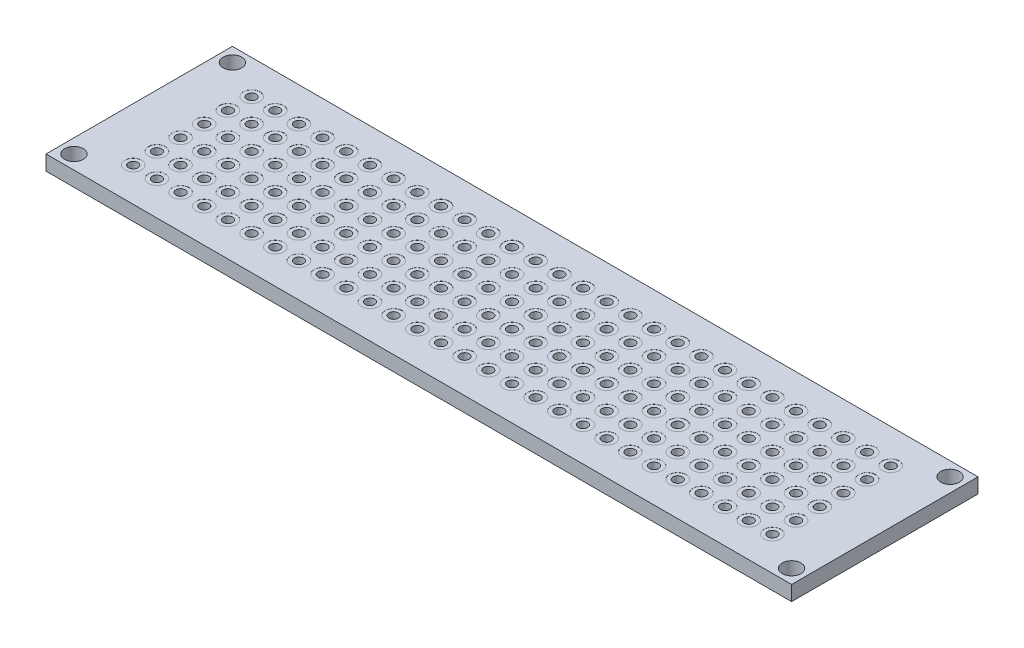
from build123d import *

# Parameters (mm, degrees)
SKETCH1_W           = 80
SKETCH1_H           = 20
SKETCH1_R           = 0.5
SKETCH1_R_2         = 1
BOSS_EXTRUDE1_DEPTH = 1.6
SKETCH2_R           = 0.9
CUT_EXTRUDE1_DEPTH  = 0.01
SKETCH3_R           = 0.9
CUT_EXTRUDE2_DEPTH  = 0.01


with BuildPart() as part:
    # Sketch1 → Boss-Extrude1 (new body)
    with BuildSketch(Plane(origin=(0, 0, 0), x_dir=(1, 0, 0), z_dir=(0, 1, 0))):
        with Locations((40, 10)):
            Rectangle(SKETCH1_W, SKETCH1_H)
        with Locations((5.71, 16.35)):
            Circle(SKETCH1_R, mode=Mode.SUBTRACT)
        with Locations((5.71, 13.81)):
            Circle(SKETCH1_R, mode=Mode.SUBTRACT)
        with Locations((5.71, 11.27)):
            Circle(SKETCH1_R, mode=Mode.SUBTRACT)
        with Locations((5.71, 8.73)):
            Circle(SKETCH1_R, mode=Mode.SUBTRACT)
        with Locations((5.71, 6.19)):
            Circle(SKETCH1_R, mode=Mode.SUBTRACT)
        with Locations((5.71, 3.65)):
            Circle(SKETCH1_R, mode=Mode.SUBTRACT)
        with Locations((8.25, 16.35)):
            Circle(SKETCH1_R, mode=Mode.SUBTRACT)
        with Locations((8.25, 13.81)):
            Circle(SKETCH1_R, mode=Mode.SUBTRACT)
        with Locations((8.25, 11.27)):
            Circle(SKETCH1_R, mode=Mode.SUBTRACT)
        with Locations((8.25, 8.73)):
            Circle(SKETCH1_R, mode=Mode.SUBTRACT)
        with Locations((8.25, 6.19)):
            Circle(SKETCH1_R, mode=Mode.SUBTRACT)
        with Locations((8.25, 3.65)):
            Circle(SKETCH1_R, mode=Mode.SUBTRACT)
        with Locations((10.79, 16.35)):
            Circle(SKETCH1_R, mode=Mode.SUBTRACT)
        with Locations((10.79, 13.81)):
            Circle(SKETCH1_R, mode=Mode.SUBTRACT)
        with Locations((10.79, 11.27)):
            Circle(SKETCH1_R, mode=Mode.SUBTRACT)
        with Locations((10.79, 8.73)):
            Circle(SKETCH1_R, mode=Mode.SUBTRACT)
        with Locations((10.79, 6.19)):
            Circle(SKETCH1_R, mode=Mode.SUBTRACT)
        with Locations((10.79, 3.65)):
            Circle(SKETCH1_R, mode=Mode.SUBTRACT)
        with Locations((13.33, 16.35)):
            Circle(SKETCH1_R, mode=Mode.SUBTRACT)
        with Locations((13.33, 13.81)):
            Circle(SKETCH1_R, mode=Mode.SUBTRACT)
        with Locations((13.33, 11.27)):
            Circle(SKETCH1_R, mode=Mode.SUBTRACT)
        with Locations((13.33, 8.73)):
            Circle(SKETCH1_R, mode=Mode.SUBTRACT)
        with Locations((13.33, 6.19)):
            Circle(SKETCH1_R, mode=Mode.SUBTRACT)
        with Locations((13.33, 3.65)):
            Circle(SKETCH1_R, mode=Mode.SUBTRACT)
        with Locations((15.87, 16.35)):
            Circle(SKETCH1_R, mode=Mode.SUBTRACT)
        with Locations((15.87, 13.81)):
            Circle(SKETCH1_R, mode=Mode.SUBTRACT)
        with Locations((15.87, 11.27)):
            Circle(SKETCH1_R, mode=Mode.SUBTRACT)
        with Locations((15.87, 8.73)):
            Circle(SKETCH1_R, mode=Mode.SUBTRACT)
        with Locations((15.87, 6.19)):
            Circle(SKETCH1_R, mode=Mode.SUBTRACT)
        with Locations((15.87, 3.65)):
            Circle(SKETCH1_R, mode=Mode.SUBTRACT)
        with Locations((18.41, 16.35)):
            Circle(SKETCH1_R, mode=Mode.SUBTRACT)
        with Locations((18.41, 13.81)):
            Circle(SKETCH1_R, mode=Mode.SUBTRACT)
        with Locations((18.41, 11.27)):
            Circle(SKETCH1_R, mode=Mode.SUBTRACT)
        with Locations((18.41, 8.73)):
            Circle(SKETCH1_R, mode=Mode.SUBTRACT)
        with Locations((18.41, 6.19)):
            Circle(SKETCH1_R, mode=Mode.SUBTRACT)
        with Locations((18.41, 3.65)):
            Circle(SKETCH1_R, mode=Mode.SUBTRACT)
        with Locations((20.95, 16.35)):
            Circle(SKETCH1_R, mode=Mode.SUBTRACT)
        with Locations((20.95, 13.81)):
            Circle(SKETCH1_R, mode=Mode.SUBTRACT)
        with Locations((20.95, 11.27)):
            Circle(SKETCH1_R, mode=Mode.SUBTRACT)
        with Locations((20.95, 8.73)):
            Circle(SKETCH1_R, mode=Mode.SUBTRACT)
        with Locations((20.95, 6.19)):
            Circle(SKETCH1_R, mode=Mode.SUBTRACT)
        with Locations((20.95, 3.65)):
            Circle(SKETCH1_R, mode=Mode.SUBTRACT)
        with Locations((23.49, 16.35)):
            Circle(SKETCH1_R, mode=Mode.SUBTRACT)
        with Locations((23.49, 13.81)):
            Circle(SKETCH1_R, mode=Mode.SUBTRACT)
        with Locations((23.49, 11.27)):
            Circle(SKETCH1_R, mode=Mode.SUBTRACT)
        with Locations((23.49, 8.73)):
            Circle(SKETCH1_R, mode=Mode.SUBTRACT)
        with Locations((23.49, 6.19)):
            Circle(SKETCH1_R, mode=Mode.SUBTRACT)
        with Locations((23.49, 3.65)):
            Circle(SKETCH1_R, mode=Mode.SUBTRACT)
        with Locations((26.03, 16.35)):
            Circle(SKETCH1_R, mode=Mode.SUBTRACT)
        with Locations((26.03, 13.81)):
            Circle(SKETCH1_R, mode=Mode.SUBTRACT)
        with Locations((26.03, 11.27)):
            Circle(SKETCH1_R, mode=Mode.SUBTRACT)
        with Locations((26.03, 8.73)):
            Circle(SKETCH1_R, mode=Mode.SUBTRACT)
        with Locations((26.03, 6.19)):
            Circle(SKETCH1_R, mode=Mode.SUBTRACT)
        with Locations((26.03, 3.65)):
            Circle(SKETCH1_R, mode=Mode.SUBTRACT)
        with Locations((28.57, 16.35)):
            Circle(SKETCH1_R, mode=Mode.SUBTRACT)
        with Locations((28.57, 13.81)):
            Circle(SKETCH1_R, mode=Mode.SUBTRACT)
        with Locations((28.57, 11.27)):
            Circle(SKETCH1_R, mode=Mode.SUBTRACT)
        with Locations((28.57, 8.73)):
            Circle(SKETCH1_R, mode=Mode.SUBTRACT)
        with Locations((28.57, 6.19)):
            Circle(SKETCH1_R, mode=Mode.SUBTRACT)
        with Locations((28.57, 3.65)):
            Circle(SKETCH1_R, mode=Mode.SUBTRACT)
        with Locations((31.11, 16.35)):
            Circle(SKETCH1_R, mode=Mode.SUBTRACT)
        with Locations((31.11, 13.81)):
            Circle(SKETCH1_R, mode=Mode.SUBTRACT)
        with Locations((31.11, 11.27)):
            Circle(SKETCH1_R, mode=Mode.SUBTRACT)
        with Locations((31.11, 8.73)):
            Circle(SKETCH1_R, mode=Mode.SUBTRACT)
        with Locations((31.11, 6.19)):
            Circle(SKETCH1_R, mode=Mode.SUBTRACT)
        with Locations((31.11, 3.65)):
            Circle(SKETCH1_R, mode=Mode.SUBTRACT)
        with Locations((33.65, 16.35)):
            Circle(SKETCH1_R, mode=Mode.SUBTRACT)
        with Locations((33.65, 13.81)):
            Circle(SKETCH1_R, mode=Mode.SUBTRACT)
        with Locations((33.65, 11.27)):
            Circle(SKETCH1_R, mode=Mode.SUBTRACT)
        with Locations((33.65, 8.73)):
            Circle(SKETCH1_R, mode=Mode.SUBTRACT)
        with Locations((33.65, 6.19)):
            Circle(SKETCH1_R, mode=Mode.SUBTRACT)
        with Locations((33.65, 3.65)):
            Circle(SKETCH1_R, mode=Mode.SUBTRACT)
        with Locations((36.19, 16.35)):
            Circle(SKETCH1_R, mode=Mode.SUBTRACT)
        with Locations((36.19, 13.81)):
            Circle(SKETCH1_R, mode=Mode.SUBTRACT)
        with Locations((36.19, 11.27)):
            Circle(SKETCH1_R, mode=Mode.SUBTRACT)
        with Locations((36.19, 8.73)):
            Circle(SKETCH1_R, mode=Mode.SUBTRACT)
        with Locations((36.19, 6.19)):
            Circle(SKETCH1_R, mode=Mode.SUBTRACT)
        with Locations((36.19, 3.65)):
            Circle(SKETCH1_R, mode=Mode.SUBTRACT)
        with Locations((38.73, 16.35)):
            Circle(SKETCH1_R, mode=Mode.SUBTRACT)
        with Locations((38.73, 13.81)):
            Circle(SKETCH1_R, mode=Mode.SUBTRACT)
        with Locations((38.73, 11.27)):
            Circle(SKETCH1_R, mode=Mode.SUBTRACT)
        with Locations((38.73, 8.73)):
            Circle(SKETCH1_R, mode=Mode.SUBTRACT)
        with Locations((38.73, 6.19)):
            Circle(SKETCH1_R, mode=Mode.SUBTRACT)
        with Locations((38.73, 3.65)):
            Circle(SKETCH1_R, mode=Mode.SUBTRACT)
        with Locations((41.27, 16.35)):
            Circle(SKETCH1_R, mode=Mode.SUBTRACT)
        with Locations((41.27, 13.81)):
            Circle(SKETCH1_R, mode=Mode.SUBTRACT)
        with Locations((41.27, 11.27)):
            Circle(SKETCH1_R, mode=Mode.SUBTRACT)
        with Locations((41.27, 8.73)):
            Circle(SKETCH1_R, mode=Mode.SUBTRACT)
        with Locations((41.27, 6.19)):
            Circle(SKETCH1_R, mode=Mode.SUBTRACT)
        with Locations((41.27, 3.65)):
            Circle(SKETCH1_R, mode=Mode.SUBTRACT)
        with Locations((43.81, 16.35)):
            Circle(SKETCH1_R, mode=Mode.SUBTRACT)
        with Locations((43.81, 13.81)):
            Circle(SKETCH1_R, mode=Mode.SUBTRACT)
        with Locations((43.81, 11.27)):
            Circle(SKETCH1_R, mode=Mode.SUBTRACT)
        with Locations((43.81, 8.73)):
            Circle(SKETCH1_R, mode=Mode.SUBTRACT)
        with Locations((43.81, 6.19)):
            Circle(SKETCH1_R, mode=Mode.SUBTRACT)
        with Locations((43.81, 3.65)):
            Circle(SKETCH1_R, mode=Mode.SUBTRACT)
        with Locations((46.35, 16.35)):
            Circle(SKETCH1_R, mode=Mode.SUBTRACT)
        with Locations((46.35, 13.81)):
            Circle(SKETCH1_R, mode=Mode.SUBTRACT)
        with Locations((46.35, 11.27)):
            Circle(SKETCH1_R, mode=Mode.SUBTRACT)
        with Locations((46.35, 8.73)):
            Circle(SKETCH1_R, mode=Mode.SUBTRACT)
        with Locations((46.35, 6.19)):
            Circle(SKETCH1_R, mode=Mode.SUBTRACT)
        with Locations((46.35, 3.65)):
            Circle(SKETCH1_R, mode=Mode.SUBTRACT)
        with Locations((48.89, 16.35)):
            Circle(SKETCH1_R, mode=Mode.SUBTRACT)
        with Locations((48.89, 13.81)):
            Circle(SKETCH1_R, mode=Mode.SUBTRACT)
        with Locations((48.89, 11.27)):
            Circle(SKETCH1_R, mode=Mode.SUBTRACT)
        with Locations((48.89, 8.73)):
            Circle(SKETCH1_R, mode=Mode.SUBTRACT)
        with Locations((48.89, 6.19)):
            Circle(SKETCH1_R, mode=Mode.SUBTRACT)
        with Locations((48.89, 3.65)):
            Circle(SKETCH1_R, mode=Mode.SUBTRACT)
        with Locations((51.43, 16.35)):
            Circle(SKETCH1_R, mode=Mode.SUBTRACT)
        with Locations((51.43, 13.81)):
            Circle(SKETCH1_R, mode=Mode.SUBTRACT)
        with Locations((51.43, 11.27)):
            Circle(SKETCH1_R, mode=Mode.SUBTRACT)
        with Locations((51.43, 8.73)):
            Circle(SKETCH1_R, mode=Mode.SUBTRACT)
        with Locations((51.43, 6.19)):
            Circle(SKETCH1_R, mode=Mode.SUBTRACT)
        with Locations((51.43, 3.65)):
            Circle(SKETCH1_R, mode=Mode.SUBTRACT)
        with Locations((53.97, 16.35)):
            Circle(SKETCH1_R, mode=Mode.SUBTRACT)
        with Locations((53.97, 13.81)):
            Circle(SKETCH1_R, mode=Mode.SUBTRACT)
        with Locations((53.97, 11.27)):
            Circle(SKETCH1_R, mode=Mode.SUBTRACT)
        with Locations((53.97, 8.73)):
            Circle(SKETCH1_R, mode=Mode.SUBTRACT)
        with Locations((53.97, 6.19)):
            Circle(SKETCH1_R, mode=Mode.SUBTRACT)
        with Locations((53.97, 3.65)):
            Circle(SKETCH1_R, mode=Mode.SUBTRACT)
        with Locations((56.51, 16.35)):
            Circle(SKETCH1_R, mode=Mode.SUBTRACT)
        with Locations((56.51, 13.81)):
            Circle(SKETCH1_R, mode=Mode.SUBTRACT)
        with Locations((56.51, 11.27)):
            Circle(SKETCH1_R, mode=Mode.SUBTRACT)
        with Locations((56.51, 8.73)):
            Circle(SKETCH1_R, mode=Mode.SUBTRACT)
        with Locations((56.51, 6.19)):
            Circle(SKETCH1_R, mode=Mode.SUBTRACT)
        with Locations((56.51, 3.65)):
            Circle(SKETCH1_R, mode=Mode.SUBTRACT)
        with Locations((59.05, 16.35)):
            Circle(SKETCH1_R, mode=Mode.SUBTRACT)
        with Locations((59.05, 13.81)):
            Circle(SKETCH1_R, mode=Mode.SUBTRACT)
        with Locations((59.05, 11.27)):
            Circle(SKETCH1_R, mode=Mode.SUBTRACT)
        with Locations((59.05, 8.73)):
            Circle(SKETCH1_R, mode=Mode.SUBTRACT)
        with Locations((59.05, 6.19)):
            Circle(SKETCH1_R, mode=Mode.SUBTRACT)
        with Locations((59.05, 3.65)):
            Circle(SKETCH1_R, mode=Mode.SUBTRACT)
        with Locations((61.59, 16.35)):
            Circle(SKETCH1_R, mode=Mode.SUBTRACT)
        with Locations((61.59, 13.81)):
            Circle(SKETCH1_R, mode=Mode.SUBTRACT)
        with Locations((61.59, 11.27)):
            Circle(SKETCH1_R, mode=Mode.SUBTRACT)
        with Locations((61.59, 8.73)):
            Circle(SKETCH1_R, mode=Mode.SUBTRACT)
        with Locations((61.59, 6.19)):
            Circle(SKETCH1_R, mode=Mode.SUBTRACT)
        with Locations((61.59, 3.65)):
            Circle(SKETCH1_R, mode=Mode.SUBTRACT)
        with Locations((64.13, 16.35)):
            Circle(SKETCH1_R, mode=Mode.SUBTRACT)
        with Locations((64.13, 13.81)):
            Circle(SKETCH1_R, mode=Mode.SUBTRACT)
        with Locations((64.13, 11.27)):
            Circle(SKETCH1_R, mode=Mode.SUBTRACT)
        with Locations((64.13, 8.73)):
            Circle(SKETCH1_R, mode=Mode.SUBTRACT)
        with Locations((64.13, 6.19)):
            Circle(SKETCH1_R, mode=Mode.SUBTRACT)
        with Locations((64.13, 3.65)):
            Circle(SKETCH1_R, mode=Mode.SUBTRACT)
        with Locations((66.67, 16.35)):
            Circle(SKETCH1_R, mode=Mode.SUBTRACT)
        with Locations((66.67, 13.81)):
            Circle(SKETCH1_R, mode=Mode.SUBTRACT)
        with Locations((66.67, 11.27)):
            Circle(SKETCH1_R, mode=Mode.SUBTRACT)
        with Locations((66.67, 8.73)):
            Circle(SKETCH1_R, mode=Mode.SUBTRACT)
        with Locations((66.67, 6.19)):
            Circle(SKETCH1_R, mode=Mode.SUBTRACT)
        with Locations((66.67, 3.65)):
            Circle(SKETCH1_R, mode=Mode.SUBTRACT)
        with Locations((69.21, 16.35)):
            Circle(SKETCH1_R, mode=Mode.SUBTRACT)
        with Locations((69.21, 13.81)):
            Circle(SKETCH1_R, mode=Mode.SUBTRACT)
        with Locations((69.21, 11.27)):
            Circle(SKETCH1_R, mode=Mode.SUBTRACT)
        with Locations((69.21, 8.73)):
            Circle(SKETCH1_R, mode=Mode.SUBTRACT)
        with Locations((69.21, 6.19)):
            Circle(SKETCH1_R, mode=Mode.SUBTRACT)
        with Locations((69.21, 3.65)):
            Circle(SKETCH1_R, mode=Mode.SUBTRACT)
        with Locations((71.75, 16.35)):
            Circle(SKETCH1_R, mode=Mode.SUBTRACT)
        with Locations((71.75, 13.81)):
            Circle(SKETCH1_R, mode=Mode.SUBTRACT)
        with Locations((71.75, 11.27)):
            Circle(SKETCH1_R, mode=Mode.SUBTRACT)
        with Locations((71.75, 8.73)):
            Circle(SKETCH1_R, mode=Mode.SUBTRACT)
        with Locations((71.75, 6.19)):
            Circle(SKETCH1_R, mode=Mode.SUBTRACT)
        with Locations((71.75, 3.65)):
            Circle(SKETCH1_R, mode=Mode.SUBTRACT)
        with Locations((74.29, 16.35)):
            Circle(SKETCH1_R, mode=Mode.SUBTRACT)
        with Locations((74.29, 13.81)):
            Circle(SKETCH1_R, mode=Mode.SUBTRACT)
        with Locations((74.29, 11.27)):
            Circle(SKETCH1_R, mode=Mode.SUBTRACT)
        with Locations((74.29, 8.73)):
            Circle(SKETCH1_R, mode=Mode.SUBTRACT)
        with Locations((74.29, 6.19)):
            Circle(SKETCH1_R, mode=Mode.SUBTRACT)
        with Locations((74.29, 3.65)):
            Circle(SKETCH1_R, mode=Mode.SUBTRACT)
        with Locations((1.5, 18.5)):
            Circle(SKETCH1_R_2, mode=Mode.SUBTRACT)
        with Locations((78.5, 18.5)):
            Circle(SKETCH1_R_2, mode=Mode.SUBTRACT)
        with Locations((1.5, 1.5)):
            Circle(SKETCH1_R_2, mode=Mode.SUBTRACT)
        with Locations((78.5, 1.5)):
            Circle(SKETCH1_R_2, mode=Mode.SUBTRACT)
    extrude(amount=BOSS_EXTRUDE1_DEPTH)

    # Sketch2 → Cut-Extrude1 (cut)
    with BuildSketch(Plane(origin=(0, 1.6, 0), x_dir=(1, 0, 0), z_dir=(0, 1, 0))):
        with Locations((5.71, 16.35)):
            Circle(SKETCH2_R)
        with Locations((8.25, 16.35)):
            Circle(SKETCH2_R)
        with Locations((10.79, 16.35)):
            Circle(SKETCH2_R)
        with Locations((13.33, 16.35)):
            Circle(SKETCH2_R)
        with Locations((15.87, 16.35)):
            Circle(SKETCH2_R)
        with Locations((18.41, 16.35)):
            Circle(SKETCH2_R)
        with Locations((20.95, 16.35)):
            Circle(SKETCH2_R)
        with Locations((23.49, 16.35)):
            Circle(SKETCH2_R)
        with Locations((26.03, 16.35)):
            Circle(SKETCH2_R)
        with Locations((28.57, 16.35)):
            Circle(SKETCH2_R)
        with Locations((31.11, 16.35)):
            Circle(SKETCH2_R)
        with Locations((33.65, 16.35)):
            Circle(SKETCH2_R)
        with Locations((36.19, 16.35)):
            Circle(SKETCH2_R)
        with Locations((38.73, 16.35)):
            Circle(SKETCH2_R)
        with Locations((41.27, 16.35)):
            Circle(SKETCH2_R)
        with Locations((43.81, 16.35)):
            Circle(SKETCH2_R)
        with Locations((46.35, 16.35)):
            Circle(SKETCH2_R)
        with Locations((48.89, 16.35)):
            Circle(SKETCH2_R)
        with Locations((51.43, 16.35)):
            Circle(SKETCH2_R)
        with Locations((53.97, 16.35)):
            Circle(SKETCH2_R)
        with Locations((56.51, 16.35)):
            Circle(SKETCH2_R)
        with Locations((59.05, 16.35)):
            Circle(SKETCH2_R)
        with Locations((61.59, 16.35)):
            Circle(SKETCH2_R)
        with Locations((64.13, 16.35)):
            Circle(SKETCH2_R)
        with Locations((66.67, 16.35)):
            Circle(SKETCH2_R)
        with Locations((69.21, 16.35)):
            Circle(SKETCH2_R)
        with Locations((71.75, 16.35)):
            Circle(SKETCH2_R)
        with Locations((74.29, 16.35)):
            Circle(SKETCH2_R)
        with Locations((8.25, 13.81)):
            Circle(SKETCH2_R)
        with Locations((10.79, 13.81)):
            Circle(SKETCH2_R)
        with Locations((13.33, 13.81)):
            Circle(SKETCH2_R)
        with Locations((15.87, 13.81)):
            Circle(SKETCH2_R)
        with Locations((18.41, 13.81)):
            Circle(SKETCH2_R)
        with Locations((20.95, 13.81)):
            Circle(SKETCH2_R)
        with Locations((23.49, 13.81)):
            Circle(SKETCH2_R)
        with Locations((26.03, 13.81)):
            Circle(SKETCH2_R)
        with Locations((28.57, 13.81)):
            Circle(SKETCH2_R)
        with Locations((31.11, 13.81)):
            Circle(SKETCH2_R)
        with Locations((33.65, 13.81)):
            Circle(SKETCH2_R)
        with Locations((36.19, 13.81)):
            Circle(SKETCH2_R)
        with Locations((38.73, 13.81)):
            Circle(SKETCH2_R)
        with Locations((41.27, 13.81)):
            Circle(SKETCH2_R)
        with Locations((43.81, 13.81)):
            Circle(SKETCH2_R)
        with Locations((46.35, 13.81)):
            Circle(SKETCH2_R)
        with Locations((48.89, 13.81)):
            Circle(SKETCH2_R)
        with Locations((51.43, 13.81)):
            Circle(SKETCH2_R)
        with Locations((53.97, 13.81)):
            Circle(SKETCH2_R)
        with Locations((56.51, 13.81)):
            Circle(SKETCH2_R)
        with Locations((59.05, 13.81)):
            Circle(SKETCH2_R)
        with Locations((61.59, 13.81)):
            Circle(SKETCH2_R)
        with Locations((64.13, 13.81)):
            Circle(SKETCH2_R)
        with Locations((66.67, 13.81)):
            Circle(SKETCH2_R)
        with Locations((69.21, 13.81)):
            Circle(SKETCH2_R)
        with Locations((71.75, 13.81)):
            Circle(SKETCH2_R)
        with Locations((74.29, 13.81)):
            Circle(SKETCH2_R)
        with Locations((8.25, 11.27)):
            Circle(SKETCH2_R)
        with Locations((10.79, 11.27)):
            Circle(SKETCH2_R)
        with Locations((13.33, 11.27)):
            Circle(SKETCH2_R)
        with Locations((15.87, 11.27)):
            Circle(SKETCH2_R)
        with Locations((18.41, 11.27)):
            Circle(SKETCH2_R)
        with Locations((20.95, 11.27)):
            Circle(SKETCH2_R)
        with Locations((23.49, 11.27)):
            Circle(SKETCH2_R)
        with Locations((26.03, 11.27)):
            Circle(SKETCH2_R)
        with Locations((28.57, 11.27)):
            Circle(SKETCH2_R)
        with Locations((31.11, 11.27)):
            Circle(SKETCH2_R)
        with Locations((33.65, 11.27)):
            Circle(SKETCH2_R)
        with Locations((36.19, 11.27)):
            Circle(SKETCH2_R)
        with Locations((38.73, 11.27)):
            Circle(SKETCH2_R)
        with Locations((41.27, 11.27)):
            Circle(SKETCH2_R)
        with Locations((43.81, 11.27)):
            Circle(SKETCH2_R)
        with Locations((46.35, 11.27)):
            Circle(SKETCH2_R)
        with Locations((48.89, 11.27)):
            Circle(SKETCH2_R)
        with Locations((51.43, 11.27)):
            Circle(SKETCH2_R)
        with Locations((53.97, 11.27)):
            Circle(SKETCH2_R)
        with Locations((56.51, 11.27)):
            Circle(SKETCH2_R)
        with Locations((59.05, 11.27)):
            Circle(SKETCH2_R)
        with Locations((61.59, 11.27)):
            Circle(SKETCH2_R)
        with Locations((64.13, 11.27)):
            Circle(SKETCH2_R)
        with Locations((66.67, 11.27)):
            Circle(SKETCH2_R)
        with Locations((69.21, 11.27)):
            Circle(SKETCH2_R)
        with Locations((71.75, 11.27)):
            Circle(SKETCH2_R)
        with Locations((74.29, 11.27)):
            Circle(SKETCH2_R)
        with Locations((8.25, 8.73)):
            Circle(SKETCH2_R)
        with Locations((10.79, 8.73)):
            Circle(SKETCH2_R)
        with Locations((13.33, 8.73)):
            Circle(SKETCH2_R)
        with Locations((15.87, 8.73)):
            Circle(SKETCH2_R)
        with Locations((18.41, 8.73)):
            Circle(SKETCH2_R)
        with Locations((20.95, 8.73)):
            Circle(SKETCH2_R)
        with Locations((23.49, 8.73)):
            Circle(SKETCH2_R)
        with Locations((26.03, 8.73)):
            Circle(SKETCH2_R)
        with Locations((28.57, 8.73)):
            Circle(SKETCH2_R)
        with Locations((31.11, 8.73)):
            Circle(SKETCH2_R)
        with Locations((33.65, 8.73)):
            Circle(SKETCH2_R)
        with Locations((36.19, 8.73)):
            Circle(SKETCH2_R)
        with Locations((38.73, 8.73)):
            Circle(SKETCH2_R)
        with Locations((41.27, 8.73)):
            Circle(SKETCH2_R)
        with Locations((43.81, 8.73)):
            Circle(SKETCH2_R)
        with Locations((46.35, 8.73)):
            Circle(SKETCH2_R)
        with Locations((48.89, 8.73)):
            Circle(SKETCH2_R)
        with Locations((51.43, 8.73)):
            Circle(SKETCH2_R)
        with Locations((53.97, 8.73)):
            Circle(SKETCH2_R)
        with Locations((56.51, 8.73)):
            Circle(SKETCH2_R)
        with Locations((59.05, 8.73)):
            Circle(SKETCH2_R)
        with Locations((61.59, 8.73)):
            Circle(SKETCH2_R)
        with Locations((64.13, 8.73)):
            Circle(SKETCH2_R)
        with Locations((66.67, 8.73)):
            Circle(SKETCH2_R)
        with Locations((69.21, 8.73)):
            Circle(SKETCH2_R)
        with Locations((71.75, 8.73)):
            Circle(SKETCH2_R)
        with Locations((74.29, 8.73)):
            Circle(SKETCH2_R)
        with Locations((8.25, 6.19)):
            Circle(SKETCH2_R)
        with Locations((10.79, 6.19)):
            Circle(SKETCH2_R)
        with Locations((13.33, 6.19)):
            Circle(SKETCH2_R)
        with Locations((15.87, 6.19)):
            Circle(SKETCH2_R)
        with Locations((18.41, 6.19)):
            Circle(SKETCH2_R)
        with Locations((20.95, 6.19)):
            Circle(SKETCH2_R)
        with Locations((23.49, 6.19)):
            Circle(SKETCH2_R)
        with Locations((26.03, 6.19)):
            Circle(SKETCH2_R)
        with Locations((28.57, 6.19)):
            Circle(SKETCH2_R)
        with Locations((31.11, 6.19)):
            Circle(SKETCH2_R)
        with Locations((33.65, 6.19)):
            Circle(SKETCH2_R)
        with Locations((36.19, 6.19)):
            Circle(SKETCH2_R)
        with Locations((38.73, 6.19)):
            Circle(SKETCH2_R)
        with Locations((41.27, 6.19)):
            Circle(SKETCH2_R)
        with Locations((43.81, 6.19)):
            Circle(SKETCH2_R)
        with Locations((46.35, 6.19)):
            Circle(SKETCH2_R)
        with Locations((48.89, 6.19)):
            Circle(SKETCH2_R)
        with Locations((51.43, 6.19)):
            Circle(SKETCH2_R)
        with Locations((53.97, 6.19)):
            Circle(SKETCH2_R)
        with Locations((56.51, 6.19)):
            Circle(SKETCH2_R)
        with Locations((59.05, 6.19)):
            Circle(SKETCH2_R)
        with Locations((61.59, 6.19)):
            Circle(SKETCH2_R)
        with Locations((64.13, 6.19)):
            Circle(SKETCH2_R)
        with Locations((66.67, 6.19)):
            Circle(SKETCH2_R)
        with Locations((69.21, 6.19)):
            Circle(SKETCH2_R)
        with Locations((71.75, 6.19)):
            Circle(SKETCH2_R)
        with Locations((74.29, 6.19)):
            Circle(SKETCH2_R)
        with Locations((8.25, 3.65)):
            Circle(SKETCH2_R)
        with Locations((10.79, 3.65)):
            Circle(SKETCH2_R)
        with Locations((13.33, 3.65)):
            Circle(SKETCH2_R)
        with Locations((15.87, 3.65)):
            Circle(SKETCH2_R)
        with Locations((18.41, 3.65)):
            Circle(SKETCH2_R)
        with Locations((20.95, 3.65)):
            Circle(SKETCH2_R)
        with Locations((23.49, 3.65)):
            Circle(SKETCH2_R)
        with Locations((26.03, 3.65)):
            Circle(SKETCH2_R)
        with Locations((28.57, 3.65)):
            Circle(SKETCH2_R)
        with Locations((31.11, 3.65)):
            Circle(SKETCH2_R)
        with Locations((33.65, 3.65)):
            Circle(SKETCH2_R)
        with Locations((36.19, 3.65)):
            Circle(SKETCH2_R)
        with Locations((38.73, 3.65)):
            Circle(SKETCH2_R)
        with Locations((41.27, 3.65)):
            Circle(SKETCH2_R)
        with Locations((43.81, 3.65)):
            Circle(SKETCH2_R)
        with Locations((46.35, 3.65)):
            Circle(SKETCH2_R)
        with Locations((48.89, 3.65)):
            Circle(SKETCH2_R)
        with Locations((51.43, 3.65)):
            Circle(SKETCH2_R)
        with Locations((53.97, 3.65)):
            Circle(SKETCH2_R)
        with Locations((56.51, 3.65)):
            Circle(SKETCH2_R)
        with Locations((59.05, 3.65)):
            Circle(SKETCH2_R)
        with Locations((61.59, 3.65)):
            Circle(SKETCH2_R)
        with Locations((64.13, 3.65)):
            Circle(SKETCH2_R)
        with Locations((66.67, 3.65)):
            Circle(SKETCH2_R)
        with Locations((69.21, 3.65)):
            Circle(SKETCH2_R)
        with Locations((71.75, 3.65)):
            Circle(SKETCH2_R)
        with Locations((74.29, 3.65)):
            Circle(SKETCH2_R)
        with Locations((5.71, 13.81)):
            Circle(SKETCH2_R)
        with Locations((5.71, 11.27)):
            Circle(SKETCH2_R)
        with Locations((5.71, 8.73)):
            Circle(SKETCH2_R)
        with Locations((5.71, 6.19)):
            Circle(SKETCH2_R)
        with Locations((5.71, 3.65)):
            Circle(SKETCH2_R)
    extrude(amount=-CUT_EXTRUDE1_DEPTH, mode=Mode.SUBTRACT)

    # Sketch3 → Cut-Extrude2 (cut)
    with BuildSketch(Plane.XZ):
        with Locations((20.95, -3.65)):
            Circle(SKETCH3_R)
        with Locations((18.41, -3.65)):
            Circle(SKETCH3_R)
        with Locations((15.87, -3.65)):
            Circle(SKETCH3_R)
        with Locations((13.33, -3.65)):
            Circle(SKETCH3_R)
        with Locations((10.79, -3.65)):
            Circle(SKETCH3_R)
        with Locations((8.25, -3.65)):
            Circle(SKETCH3_R)
        with Locations((74.29, -6.19)):
            Circle(SKETCH3_R)
        with Locations((71.75, -6.19)):
            Circle(SKETCH3_R)
        with Locations((18.41, -16.35)):
            Circle(SKETCH3_R)
        with Locations((15.87, -16.35)):
            Circle(SKETCH3_R)
        with Locations((13.33, -16.35)):
            Circle(SKETCH3_R)
        with Locations((10.79, -16.35)):
            Circle(SKETCH3_R)
        with Locations((8.25, -16.35)):
            Circle(SKETCH3_R)
        with Locations((5.71, -16.35)):
            Circle(SKETCH3_R)
        with Locations((41.27, -3.65)):
            Circle(SKETCH3_R)
        with Locations((38.73, -3.65)):
            Circle(SKETCH3_R)
        with Locations((36.19, -3.65)):
            Circle(SKETCH3_R)
        with Locations((33.65, -3.65)):
            Circle(SKETCH3_R)
        with Locations((31.11, -3.65)):
            Circle(SKETCH3_R)
        with Locations((28.57, -3.65)):
            Circle(SKETCH3_R)
        with Locations((26.03, -3.65)):
            Circle(SKETCH3_R)
        with Locations((23.49, -3.65)):
            Circle(SKETCH3_R)
        with Locations((38.73, -16.35)):
            Circle(SKETCH3_R)
        with Locations((36.19, -16.35)):
            Circle(SKETCH3_R)
        with Locations((33.65, -16.35)):
            Circle(SKETCH3_R)
        with Locations((31.11, -16.35)):
            Circle(SKETCH3_R)
        with Locations((28.57, -16.35)):
            Circle(SKETCH3_R)
        with Locations((26.03, -16.35)):
            Circle(SKETCH3_R)
        with Locations((23.49, -16.35)):
            Circle(SKETCH3_R)
        with Locations((20.95, -16.35)):
            Circle(SKETCH3_R)
        with Locations((61.59, -3.65)):
            Circle(SKETCH3_R)
        with Locations((59.05, -3.65)):
            Circle(SKETCH3_R)
        with Locations((56.51, -3.65)):
            Circle(SKETCH3_R)
        with Locations((53.97, -3.65)):
            Circle(SKETCH3_R)
        with Locations((51.43, -3.65)):
            Circle(SKETCH3_R)
        with Locations((48.89, -3.65)):
            Circle(SKETCH3_R)
        with Locations((46.35, -3.65)):
            Circle(SKETCH3_R)
        with Locations((43.81, -3.65)):
            Circle(SKETCH3_R)
        with Locations((59.05, -16.35)):
            Circle(SKETCH3_R)
        with Locations((56.51, -16.35)):
            Circle(SKETCH3_R)
        with Locations((53.97, -16.35)):
            Circle(SKETCH3_R)
        with Locations((51.43, -16.35)):
            Circle(SKETCH3_R)
        with Locations((48.89, -16.35)):
            Circle(SKETCH3_R)
        with Locations((46.35, -16.35)):
            Circle(SKETCH3_R)
        with Locations((43.81, -16.35)):
            Circle(SKETCH3_R)
        with Locations((41.27, -16.35)):
            Circle(SKETCH3_R)
        with Locations((5.71, -8.73)):
            Circle(SKETCH3_R)
        with Locations((5.71, -11.27)):
            Circle(SKETCH3_R)
        with Locations((5.71, -13.81)):
            Circle(SKETCH3_R)
        with Locations((74.29, -3.65)):
            Circle(SKETCH3_R)
        with Locations((71.75, -3.65)):
            Circle(SKETCH3_R)
        with Locations((69.21, -3.65)):
            Circle(SKETCH3_R)
        with Locations((66.67, -3.65)):
            Circle(SKETCH3_R)
        with Locations((64.13, -3.65)):
            Circle(SKETCH3_R)
        with Locations((10.79, -13.81)):
            Circle(SKETCH3_R)
        with Locations((8.25, -13.81)):
            Circle(SKETCH3_R)
        with Locations((74.29, -16.35)):
            Circle(SKETCH3_R)
        with Locations((71.75, -16.35)):
            Circle(SKETCH3_R)
        with Locations((69.21, -16.35)):
            Circle(SKETCH3_R)
        with Locations((66.67, -16.35)):
            Circle(SKETCH3_R)
        with Locations((64.13, -16.35)):
            Circle(SKETCH3_R)
        with Locations((61.59, -16.35)):
            Circle(SKETCH3_R)
        with Locations((5.71, -3.65)):
            Circle(SKETCH3_R)
        with Locations((5.71, -6.19)):
            Circle(SKETCH3_R)
        with Locations((31.11, -13.81)):
            Circle(SKETCH3_R)
        with Locations((28.57, -13.81)):
            Circle(SKETCH3_R)
        with Locations((26.03, -13.81)):
            Circle(SKETCH3_R)
        with Locations((23.49, -13.81)):
            Circle(SKETCH3_R)
        with Locations((20.95, -13.81)):
            Circle(SKETCH3_R)
        with Locations((18.41, -13.81)):
            Circle(SKETCH3_R)
        with Locations((15.87, -13.81)):
            Circle(SKETCH3_R)
        with Locations((13.33, -13.81)):
            Circle(SKETCH3_R)
        with Locations((51.43, -13.81)):
            Circle(SKETCH3_R)
        with Locations((48.89, -13.81)):
            Circle(SKETCH3_R)
        with Locations((46.35, -13.81)):
            Circle(SKETCH3_R)
        with Locations((43.81, -13.81)):
            Circle(SKETCH3_R)
        with Locations((41.27, -13.81)):
            Circle(SKETCH3_R)
        with Locations((38.73, -13.81)):
            Circle(SKETCH3_R)
        with Locations((36.19, -13.81)):
            Circle(SKETCH3_R)
        with Locations((33.65, -13.81)):
            Circle(SKETCH3_R)
        with Locations((71.75, -13.81)):
            Circle(SKETCH3_R)
        with Locations((69.21, -13.81)):
            Circle(SKETCH3_R)
        with Locations((66.67, -13.81)):
            Circle(SKETCH3_R)
        with Locations((64.13, -13.81)):
            Circle(SKETCH3_R)
        with Locations((61.59, -13.81)):
            Circle(SKETCH3_R)
        with Locations((59.05, -13.81)):
            Circle(SKETCH3_R)
        with Locations((56.51, -13.81)):
            Circle(SKETCH3_R)
        with Locations((53.97, -13.81)):
            Circle(SKETCH3_R)
        with Locations((23.49, -11.27)):
            Circle(SKETCH3_R)
        with Locations((20.95, -11.27)):
            Circle(SKETCH3_R)
        with Locations((18.41, -11.27)):
            Circle(SKETCH3_R)
        with Locations((15.87, -11.27)):
            Circle(SKETCH3_R)
        with Locations((13.33, -11.27)):
            Circle(SKETCH3_R)
        with Locations((10.79, -11.27)):
            Circle(SKETCH3_R)
        with Locations((8.25, -11.27)):
            Circle(SKETCH3_R)
        with Locations((74.29, -13.81)):
            Circle(SKETCH3_R)
        with Locations((43.81, -11.27)):
            Circle(SKETCH3_R)
        with Locations((41.27, -11.27)):
            Circle(SKETCH3_R)
        with Locations((38.73, -11.27)):
            Circle(SKETCH3_R)
        with Locations((36.19, -11.27)):
            Circle(SKETCH3_R)
        with Locations((33.65, -11.27)):
            Circle(SKETCH3_R)
        with Locations((31.11, -11.27)):
            Circle(SKETCH3_R)
        with Locations((28.57, -11.27)):
            Circle(SKETCH3_R)
        with Locations((26.03, -11.27)):
            Circle(SKETCH3_R)
        with Locations((64.13, -11.27)):
            Circle(SKETCH3_R)
        with Locations((61.59, -11.27)):
            Circle(SKETCH3_R)
        with Locations((59.05, -11.27)):
            Circle(SKETCH3_R)
        with Locations((56.51, -11.27)):
            Circle(SKETCH3_R)
        with Locations((53.97, -11.27)):
            Circle(SKETCH3_R)
        with Locations((51.43, -11.27)):
            Circle(SKETCH3_R)
        with Locations((48.89, -11.27)):
            Circle(SKETCH3_R)
        with Locations((46.35, -11.27)):
            Circle(SKETCH3_R)
        with Locations((15.87, -8.73)):
            Circle(SKETCH3_R)
        with Locations((13.33, -8.73)):
            Circle(SKETCH3_R)
        with Locations((10.79, -8.73)):
            Circle(SKETCH3_R)
        with Locations((8.25, -8.73)):
            Circle(SKETCH3_R)
        with Locations((74.29, -11.27)):
            Circle(SKETCH3_R)
        with Locations((71.75, -11.27)):
            Circle(SKETCH3_R)
        with Locations((69.21, -11.27)):
            Circle(SKETCH3_R)
        with Locations((66.67, -11.27)):
            Circle(SKETCH3_R)
        with Locations((36.19, -8.73)):
            Circle(SKETCH3_R)
        with Locations((33.65, -8.73)):
            Circle(SKETCH3_R)
        with Locations((31.11, -8.73)):
            Circle(SKETCH3_R)
        with Locations((28.57, -8.73)):
            Circle(SKETCH3_R)
        with Locations((26.03, -8.73)):
            Circle(SKETCH3_R)
        with Locations((23.49, -8.73)):
            Circle(SKETCH3_R)
        with Locations((20.95, -8.73)):
            Circle(SKETCH3_R)
        with Locations((18.41, -8.73)):
            Circle(SKETCH3_R)
        with Locations((56.51, -8.73)):
            Circle(SKETCH3_R)
        with Locations((53.97, -8.73)):
            Circle(SKETCH3_R)
        with Locations((51.43, -8.73)):
            Circle(SKETCH3_R)
        with Locations((48.89, -8.73)):
            Circle(SKETCH3_R)
        with Locations((46.35, -8.73)):
            Circle(SKETCH3_R)
        with Locations((43.81, -8.73)):
            Circle(SKETCH3_R)
        with Locations((41.27, -8.73)):
            Circle(SKETCH3_R)
        with Locations((38.73, -8.73)):
            Circle(SKETCH3_R)
        with Locations((8.25, -6.19)):
            Circle(SKETCH3_R)
        with Locations((74.29, -8.73)):
            Circle(SKETCH3_R)
        with Locations((71.75, -8.73)):
            Circle(SKETCH3_R)
        with Locations((69.21, -8.73)):
            Circle(SKETCH3_R)
        with Locations((66.67, -8.73)):
            Circle(SKETCH3_R)
        with Locations((64.13, -8.73)):
            Circle(SKETCH3_R)
        with Locations((61.59, -8.73)):
            Circle(SKETCH3_R)
        with Locations((59.05, -8.73)):
            Circle(SKETCH3_R)
        with Locations((28.57, -6.19)):
            Circle(SKETCH3_R)
        with Locations((26.03, -6.19)):
            Circle(SKETCH3_R)
        with Locations((23.49, -6.19)):
            Circle(SKETCH3_R)
        with Locations((20.95, -6.19)):
            Circle(SKETCH3_R)
        with Locations((18.41, -6.19)):
            Circle(SKETCH3_R)
        with Locations((15.87, -6.19)):
            Circle(SKETCH3_R)
        with Locations((13.33, -6.19)):
            Circle(SKETCH3_R)
        with Locations((10.79, -6.19)):
            Circle(SKETCH3_R)
        with Locations((48.89, -6.19)):
            Circle(SKETCH3_R)
        with Locations((46.35, -6.19)):
            Circle(SKETCH3_R)
        with Locations((43.81, -6.19)):
            Circle(SKETCH3_R)
        with Locations((41.27, -6.19)):
            Circle(SKETCH3_R)
        with Locations((38.73, -6.19)):
            Circle(SKETCH3_R)
        with Locations((36.19, -6.19)):
            Circle(SKETCH3_R)
        with Locations((33.65, -6.19)):
            Circle(SKETCH3_R)
        with Locations((31.11, -6.19)):
            Circle(SKETCH3_R)
        with Locations((69.21, -6.19)):
            Circle(SKETCH3_R)
        with Locations((66.67, -6.19)):
            Circle(SKETCH3_R)
        with Locations((64.13, -6.19)):
            Circle(SKETCH3_R)
        with Locations((61.59, -6.19)):
            Circle(SKETCH3_R)
        with Locations((59.05, -6.19)):
            Circle(SKETCH3_R)
        with Locations((56.51, -6.19)):
            Circle(SKETCH3_R)
        with Locations((53.97, -6.19)):
            Circle(SKETCH3_R)
        with Locations((51.43, -6.19)):
            Circle(SKETCH3_R)
    extrude(amount=-CUT_EXTRUDE2_DEPTH, mode=Mode.SUBTRACT)


solid = part.part
